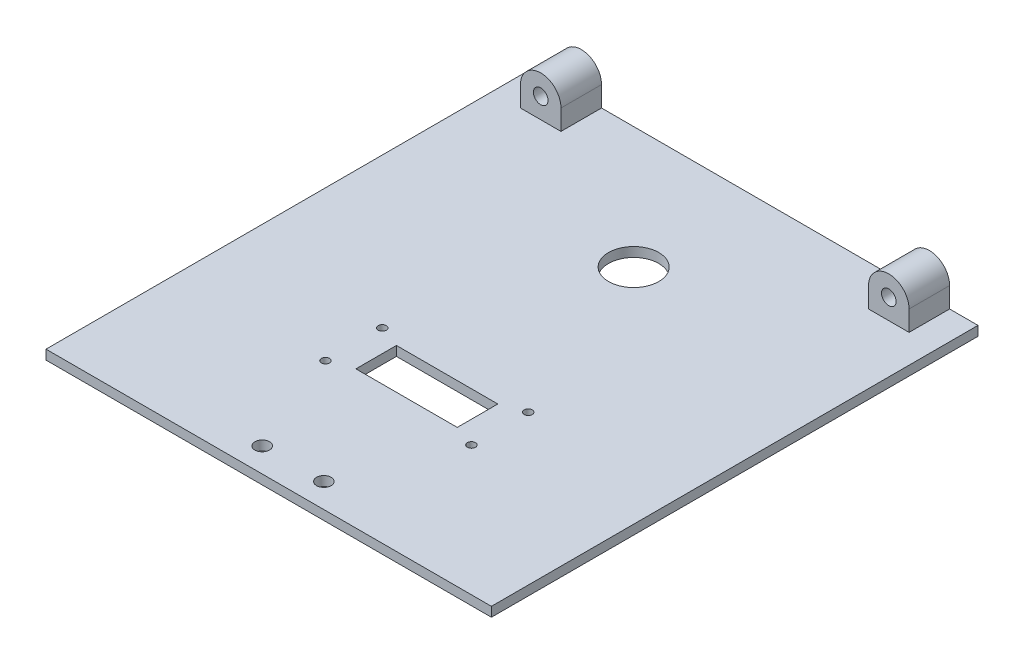
from build123d import *

# Parameters (mm, degrees)
SKETCH1_W               = 139.5
SKETCH1_H               = 152.4
BOSS_EXTRUDE1_DEPTH     = 6.35
SKETCH2_W               = 139.5
SKETCH2_H               = 152.4
CUT_EXTRUDE1_DEPTH      = 3.375
SKETCH4_R               = 2.286
BOSS_EXTRUDE3_DEPTH     = 12.7
SKETCH5_R               = 7.874
CUT_EXTRUDE2_DEPTH      = 16.675
SKETCH6_R               = 2.286
CUT_EXTRUDE3_DEPTH      = 3.975
SKETCH7_R               = 1.27
SKETCH7_W               = 31.75
SKETCH7_H               = 12.7
CUT_EXTRUDE4_DEPTH      = 1
CUT_EXTRUDE4_DEPTH_BACK = 16.675


with BuildPart() as part:
    # Sketch1 → Boss-Extrude1 (new body)
    with BuildSketch(Plane(origin=(0, 0, 0), x_dir=(1, 0, 0), z_dir=(0, 1, 0))):
        with Locations((69.75, 76.2)):
            Rectangle(SKETCH1_W, SKETCH1_H)
    extrude(amount=BOSS_EXTRUDE1_DEPTH)

    # Sketch2 → Cut-Extrude1 (cut)
    with BuildSketch(Plane(origin=(0, 6.35, 0), x_dir=(1, 0, 0), z_dir=(0, 1, 0))):
        with Locations((69.75, 76.2)):
            Rectangle(SKETCH2_W, SKETCH2_H)
    extrude(amount=-CUT_EXTRUDE1_DEPTH, mode=Mode.SUBTRACT)

    # Sketch4 → Boss-Extrude3 (add)
    with BuildSketch(Plane(origin=(0, 0, -152.4), x_dir=(-1, 0, 0), z_dir=(0, 0, -1))):
        with BuildLine():
            Line((-130.61, 9.325), (-130.61, 2.975))
            Line((-130.61, 2.975), (-117.91, 2.975))
            Line((-117.91, 2.975), (-117.91, 9.325))
            ThreePointArc((-117.91, 9.325), (-124.26, 15.675), (-130.61, 9.325))
        make_face()
        with Locations((-124.26, 9.325)):
            Circle(SKETCH4_R, mode=Mode.SUBTRACT)
        with BuildLine():
            Line((-21.59, 9.325), (-21.59, 2.975))
            Line((-21.59, 2.975), (-8.89, 2.975))
            Line((-8.89, 2.975), (-8.89, 9.325))
            ThreePointArc((-8.89, 9.325), (-15.24, 15.675), (-21.59, 9.325))
        make_face()
        with Locations((-15.24, 9.325)):
            Circle(SKETCH4_R, mode=Mode.SUBTRACT)
    extrude(amount=-BOSS_EXTRUDE3_DEPTH)

    # Sketch5 → Cut-Extrude2 (cut, through all)
    with BuildSketch(Plane.XZ):
        with Locations((69.75, -114.3)):
            Circle(SKETCH5_R)
    extrude(amount=-CUT_EXTRUDE2_DEPTH, mode=Mode.SUBTRACT)

    # Sketch6 → Cut-Extrude3 (cut, through all)
    with BuildSketch(Plane(origin=(0, 2.975, 0), x_dir=(1, 0, 0), z_dir=(0, 1, 0))):
        with Locations((60.098, 7.62)):
            Circle(SKETCH6_R)
        with Locations((79.402, 7.62)):
            Circle(SKETCH6_R)
    extrude(amount=-CUT_EXTRUDE3_DEPTH, mode=Mode.SUBTRACT)

    # Sketch7 → Cut-Extrude4 (cut, two sides)
    with BuildSketch(Plane.XZ) as cut_extrude4_sk:
        with Locations((46.89, -40.64)):
            Circle(SKETCH7_R)
        with Locations((92.61, -40.64)):
            Circle(SKETCH7_R)
        with Locations((92.61, -58.42)):
            Circle(SKETCH7_R)
        with Locations((46.89, -58.42)):
            Circle(SKETCH7_R)
        with Locations((69.75, -49.53)):
            Rectangle(SKETCH7_W, SKETCH7_H)
    extrude(amount=CUT_EXTRUDE4_DEPTH, mode=Mode.SUBTRACT)
    extrude(cut_extrude4_sk.sketch, amount=-CUT_EXTRUDE4_DEPTH_BACK, mode=Mode.SUBTRACT)


solid = part.part
